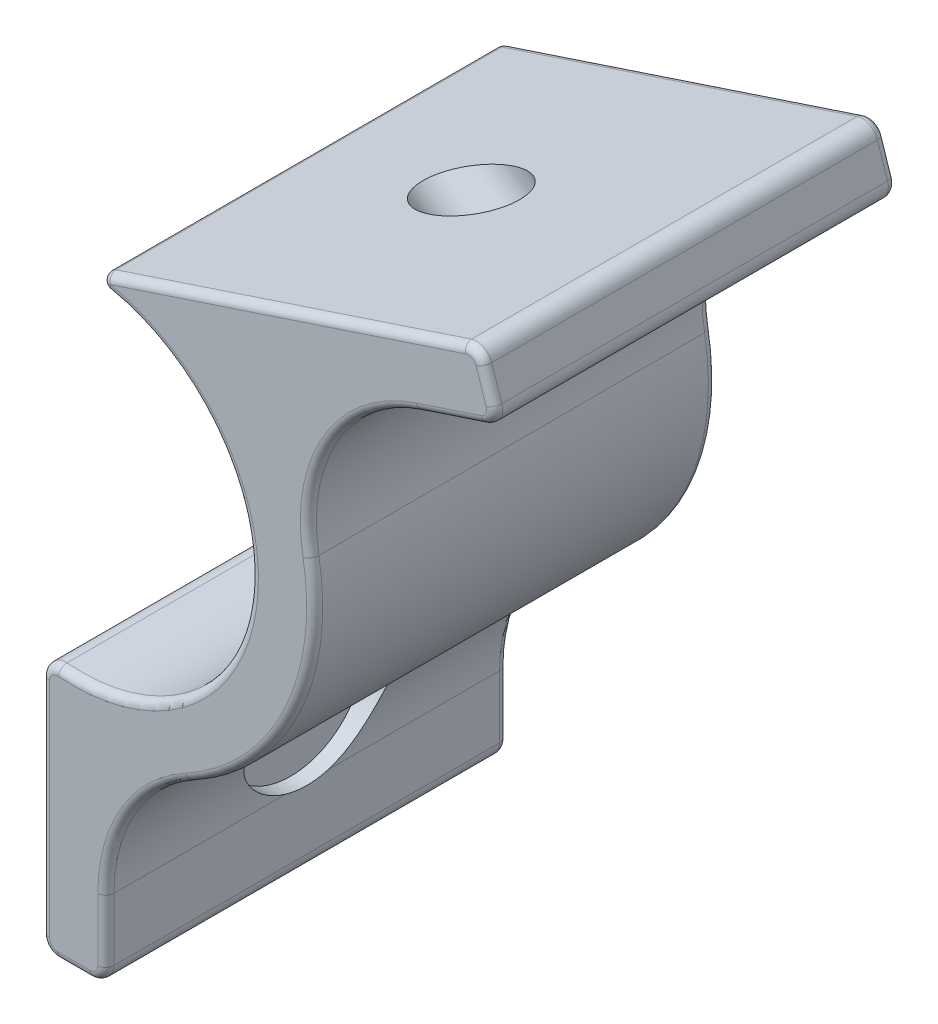
from build123d import *

# Parameters (mm, degrees)
Y_KSEKLIK_EKSTR_ZYON1_DEPTH = 25
IZIM4_R                     = 2.6
KES_EKSTR_ZYON1_DEPTH       = 9
IZIM5_R                     = 4.6
KES_EKSTR_ZYON2_DEPTH       = 6
IZIM6_R                     = 2.6
KES_EKSTR_ZYON3_DEPTH       = 36.5
IZIM7_R                     = 4.6
KES_EKSTR_ZYON4_DEPTH       = 5
RADYUS1_R                   = 0.5


with BuildPart() as part:
    # Çizim1 → Yükseklik-Ekstrüzyon1 (new body)
    with BuildSketch(Plane.XY):
        with BuildLine():
            Line((6.516322935, -38.083207178), (6.516322935, -24.224071188))
            ThreePointArc((6.516322935, -24.224071188), (6.839093945, -23.488298875), (7.599044726, -23.227498508))
            ThreePointArc((7.599044726, -23.227498508), (19.398597482, -13.819653137), (10.702548541, -1.486132448))
            ThreePointArc((10.702548541, -1.486132448), (10.303139514, -1.025885698), (10.645127383, -0.521505941))
            Line((10.645127383, -0.521505941), (32.763677784, 6.800349322))
            ThreePointArc((32.763677784, 6.800349322), (33.527004842, 6.744508119), (34.027272888, 6.165268687))
            Line((34.027272888, 6.165268687), (34.655787357, 4.266592948))
            ThreePointArc((34.655787357, 4.266592948), (34.599946154, 3.50326589), (34.020706721, 3.002997844))
            Line((34.020706721, 3.002997844), (29.970072893, 1.662125405))
            ThreePointArc((29.970072893, 1.662125405), (24.517159095, -2.720713399), (23.271180913, -9.604831589))
            ThreePointArc((23.271180913, -9.604831589), (22.043278837, -18.732259795), (15.713387532, -25.421816227))
            ThreePointArc((15.713387532, -25.421816227), (11.913144626, -29.095314243), (10.516322935, -34.192894354))
            Line((10.516322935, -34.192894354), (10.516322935, -38.083207178))
            ThreePointArc((10.516322935, -38.083207178), (10.223429716, -38.790313959), (9.516322935, -39.083207178))
            Line((9.516322935, -39.083207178), (7.516322935, -39.083207178))
            ThreePointArc((7.516322935, -39.083207178), (6.809216154, -38.790313959), (6.516322935, -38.083207178))
        make_face()
    extrude(amount=-Y_KSEKLIK_EKSTR_ZYON1_DEPTH)

    # Çizim4 → Kes-Ekstrüzyon1 (cut)
    with BuildSketch(Plane(origin=(15.516322935, 0, 0), x_dir=(0, 0, -1), z_dir=(1, 0, 0))):
        with Locations((12.5, -29.783207178)):
            Circle(IZIM4_R)
    extrude(amount=-KES_EKSTR_ZYON1_DEPTH, mode=Mode.SUBTRACT)

    # Çizim5 → Kes-Ekstrüzyon2 (cut)
    with BuildSketch(Plane(origin=(15.516322935, 0, 0), x_dir=(0, 0, -1), z_dir=(1, 0, 0))):
        with Locations((12.5, -29.783207178)):
            Circle(IZIM5_R)
    extrude(amount=-KES_EKSTR_ZYON2_DEPTH, mode=Mode.SUBTRACT)

    # Çizim6 → Kes-Ekstrüzyon3 (cut)
    with BuildSketch(Plane(origin=(20.440424649, -15.226956818, 0), x_dir=(0, 0, 1), z_dir=(0.801942288, -0.597401512, 0))):
        with Locations((-12.5, -14.66586446)):
            Circle(IZIM6_R)
    extrude(amount=-KES_EKSTR_ZYON3_DEPTH, mode=Mode.SUBTRACT)

    # Çizim7 → Kes-Ekstrüzyon4 (cut)
    with BuildSketch(Plane(origin=(20.440424649, -15.226956818, 0), x_dir=(0, 0, 1), z_dir=(0.801942288, -0.597401512, 0))):
        with Locations((-12.5, -14.66586446)):
            Circle(IZIM7_R)
    extrude(amount=-KES_EKSTR_ZYON4_DEPTH, mode=Mode.SUBTRACT)

    # Radyus1
    radyus1_edges = [part.edges().sort_by_distance(p)[0] for p in [
        (24.517159095, -2.720713399, -25),
        (10.516322935, -36.138050766, 0),
        (10.223429716, -38.790313959, 0),
        (8.516322935, -39.083207178, 0),
        (31.995389807, 2.332561624, -25),
        (6.809216154, -38.790313959, 0),
        (6.516322935, -31.153639183, 0),
        (6.839093945, -23.488298875, 0),
        (19.398597482, -13.819653137, 0),
        (10.303139514, -1.025885698, 0),
        (21.704402584, 3.13942169, 0),
        (33.527004842, 6.744508119, 0),
        (34.341530122, 5.215930817, 0),
        (34.599946154, 3.50326589, 0),
        (31.995389807, 2.332561624, 0),
        (34.599946154, 3.50326589, -25),
        (24.517159095, -2.720713399, 0),
        (22.043278837, -18.732259795, 0),
        (11.913144626, -29.095314243, 0),
        (34.341530122, 5.215930817, -25),
        (33.527004842, 6.744508119, -25),
        (21.704402584, 3.13942169, -25),
        (10.303139514, -1.025885698, -25),
        (19.398597482, -13.819653137, -25),
        (6.839093945, -23.488298875, -25),
        (6.516322935, -31.153639183, -25),
        (11.913144626, -29.095314243, -25),
        (6.809216154, -38.790313959, -25),
        (8.516322935, -39.083207178, -25),
        (10.223429716, -38.790313959, -25),
        (10.516322935, -36.138050766, -25),
        (22.043278837, -18.732259795, -25),
    ]]
    fillet(radyus1_edges, radius=RADYUS1_R)


solid = part.part
